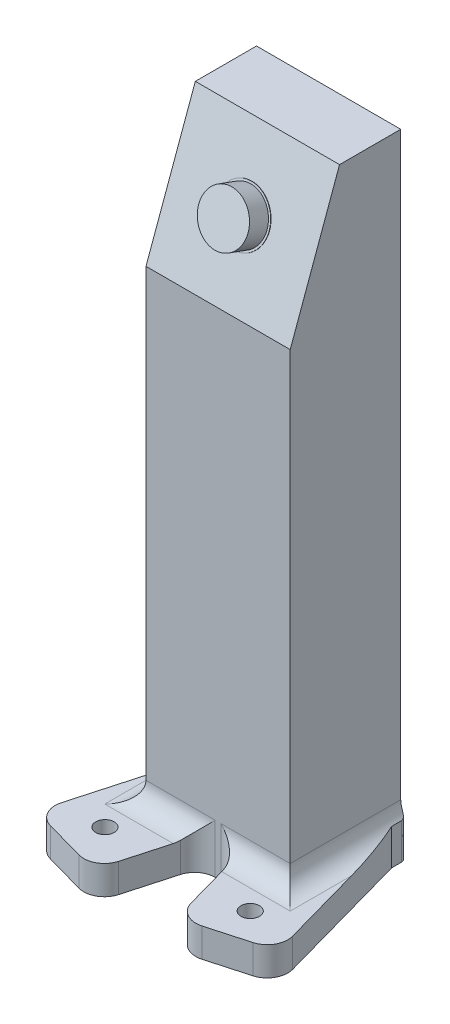
from build123d import *

# Parameters (mm, degrees)
AUFSATZ_LINEAR_AUSTRAGEN1_DEPTH = 35
SKIZZE3_R                       = 6
AUFSATZ_LINEAR_AUSTRAGEN2_DEPTH = 5
SKIZZE4_R                       = 6.5
AUFSATZ_LINEAR_AUSTRAGEN3_DEPTH = 0.1
SKIZZE9_R                       = 1.425
SCHNITT_LINEAR_AUSTRAGEN2_DEPTH = 10
SKIZZE10_R                      = 2.25
AUFSATZ_LINEAR_AUSTRAGEN4_DEPTH = 7
VERRUNDUNG1_R                   = 5
VERRUNDUNG2_R                   = 1


with BuildPart() as part:
    # Skizze1 → Aufsatz-Linear austragen1 (new body)
    with BuildSketch(Plane(origin=(0, 0, 0), x_dir=(0, 0, -1), z_dir=(1, 0, 0))):
        Polygon((0, 0), (11.970705016, 0), (26.82, 0), (26.82, 152.889241728), (11.970705016, 152.889241728), (0, 120), align=None)
    extrude(amount=AUFSATZ_LINEAR_AUSTRAGEN1_DEPTH)

    # Skizze3 → Aufsatz-Linear austragen2 (add)
    with BuildSketch(Plane(origin=(0, 14.037333413, 38.567256581), x_dir=(1, 0, 0), z_dir=(0, 0.342020143, 0.939692621))):
        with Locations((17.5, 130.263114494)):
            Circle(SKIZZE3_R)
    extrude(amount=AUFSATZ_LINEAR_AUSTRAGEN2_DEPTH)

    # Skizze4 → Aufsatz-Linear austragen3 (add)
    with BuildSketch(Plane(origin=(0, 14.037333413, 38.567256581), x_dir=(1, 0, 0), z_dir=(0, 0.342020143, 0.939692621))):
        with Locations((17.5, 130.263114494)):
            Circle(SKIZZE4_R)
    extrude(amount=AUFSATZ_LINEAR_AUSTRAGEN3_DEPTH)

    # Skizze9 → Schnitt-Linear austragen2 (cut)
    with BuildSketch(Plane.XZ):
        with Locations((17.498844944, -21.644236877)):
            Circle(SKIZZE9_R)
    extrude(amount=-SCHNITT_LINEAR_AUSTRAGEN2_DEPTH, mode=Mode.SUBTRACT)

    # Skizze10 → Aufsatz-Linear austragen4 (add)
    with BuildSketch(Plane.XZ):
        Polygon((35, -26.82), (36.222689888, -26.82), (36.222689888, -23.396698607), (46.889907729, 14.777378017), (27.627810102, 20.159904842), (21.994403466, 0), align=None)
        with Locations((35.124354886, 9.830031101)):
            Circle(SKIZZE10_R, mode=Mode.SUBTRACT)
        Polygon((-1.222689888, -26.82), (-1.222689888, -23.396698607), (-11.889907729, 14.777378017), (7.372189898, 20.159904842), (13.005596534, 0), (0, -26.82), align=None)
        with Locations((-0.124354886, 9.830031101)):
            Circle(SKIZZE10_R, mode=Mode.SUBTRACT)
    extrude(amount=-AUFSATZ_LINEAR_AUSTRAGEN4_DEPTH)

    # Verrundung1
    verrundung1_edges = [part.edges().sort_by_distance(p)[0] for p in [
        (6.502798267, 7, 0),
        (28.497201733, 7, 0),
        (35, 7, -13.41),
        (0, 7, -13.41),
        (-11.889907729, 3.5, 14.777378017),
        (7.372189898, 3.5, 20.159904842),
        (46.889907729, 3.5, 14.777378017),
        (27.627810102, 3.5, 20.159904842),
        (21.994403466, 3.5, 0),
        (13.005596534, 3.5, 0),
    ]]
    fillet(verrundung1_edges, radius=VERRUNDUNG1_R)

    # Verrundung2
    verrundung2_edges = [part.edges().sort_by_distance(p)[0] for p in [
        (36.222689888, 4.362018901, -26.82),
        (-1.222689888, 4.362018901, -26.82),
    ]]
    fillet(verrundung2_edges, radius=VERRUNDUNG2_R)


solid = part.part
